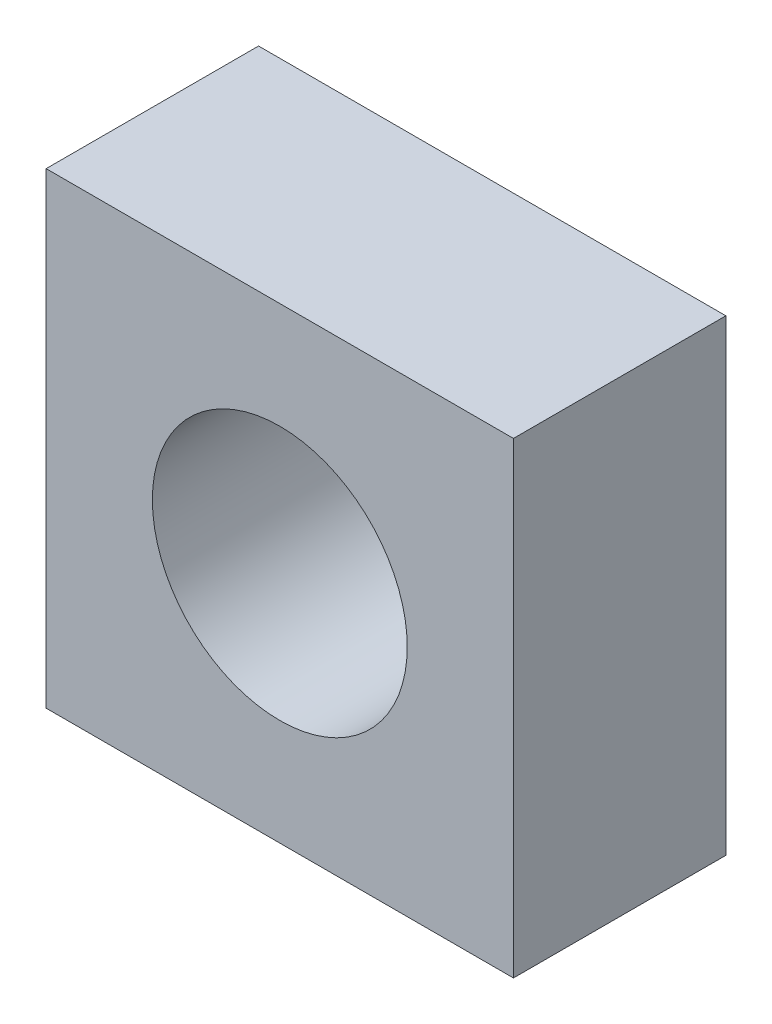
from build123d import *

# Parameters (mm, degrees)
SKETCH1_W           = 5.5
SKETCH1_H           = 5.5
SKETCH1_R           = 1.5
BOSS_EXTRUDE1_DEPTH = 2.5


with BuildPart() as part:
    # Sketch1 → Boss-Extrude1 (new body)
    with BuildSketch(Plane.XY):
        Rectangle(SKETCH1_W, SKETCH1_H)
        Circle(SKETCH1_R, mode=Mode.SUBTRACT)
    extrude(amount=BOSS_EXTRUDE1_DEPTH)


solid = part.part
